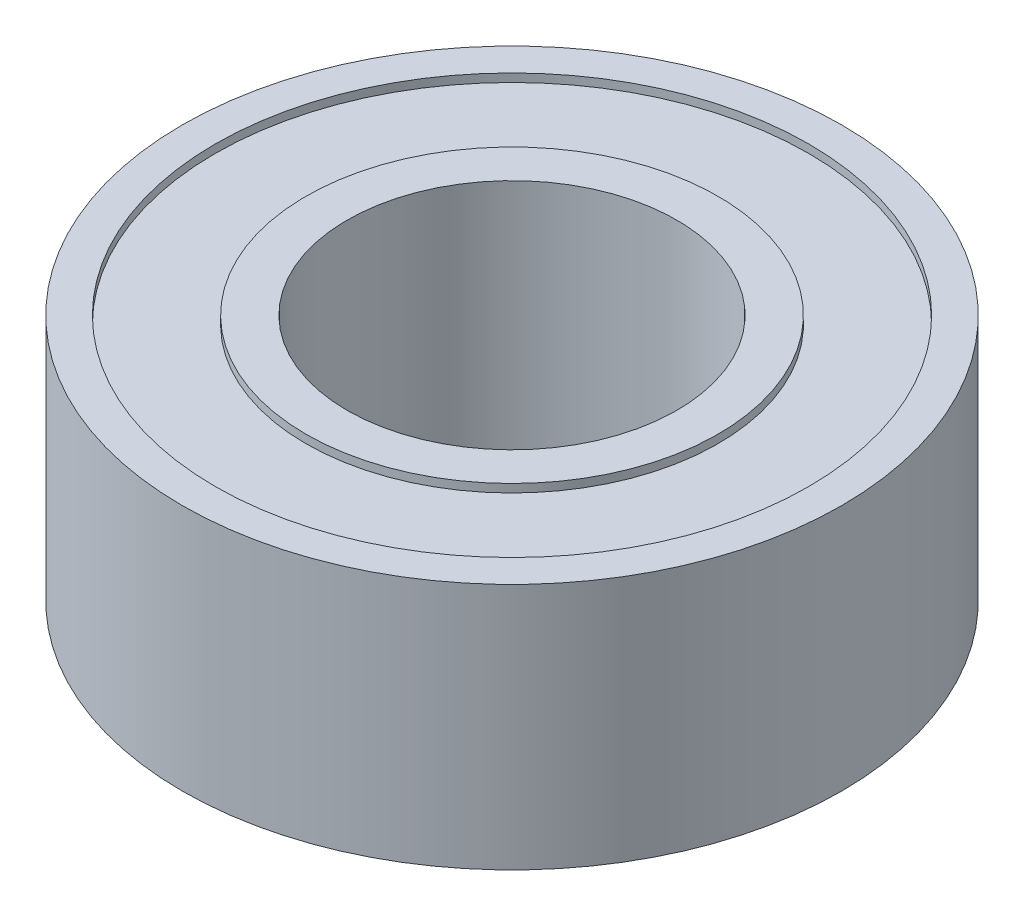
from build123d import *

# Parameters (mm, degrees)
SKETCH_1_R          = 4
SKETCH_1_R_2        = 2
EXTRUDE_1_DEPTH     = 3
SKETCH_2_R          = 3.6
SKETCH_2_R_2        = 2.5
CUT_EXTRUDE_1_DEPTH = 0.1
SKETCH_3_R          = 3.6
SKETCH_3_R_2        = 2.5
CUT_EXTRUDE_2_DEPTH = 0.1


with BuildPart() as part:
    # Эскиз1 → Бобышка-Вытянуть1 (new body)
    with BuildSketch(Plane(origin=(0, 0, 0), x_dir=(1, 0, 0), z_dir=(0, 1, 0))):
        Circle(SKETCH_1_R)
        Circle(SKETCH_1_R_2, mode=Mode.SUBTRACT)
    extrude(amount=EXTRUDE_1_DEPTH)

    # Эскиз2 → Вырез-Вытянуть1 (cut)
    with BuildSketch(Plane(origin=(0, 3, 0), x_dir=(1, 0, 0), z_dir=(0, 1, 0))):
        Circle(SKETCH_2_R)
        Circle(SKETCH_2_R_2, mode=Mode.SUBTRACT)
    extrude(amount=-CUT_EXTRUDE_1_DEPTH, mode=Mode.SUBTRACT)

    # Эскиз3 → Вырез-Вытянуть2 (cut)
    with BuildSketch(Plane.XZ):
        Circle(SKETCH_3_R)
        Circle(SKETCH_3_R_2, mode=Mode.SUBTRACT)
    extrude(amount=-CUT_EXTRUDE_2_DEPTH, mode=Mode.SUBTRACT)


solid = part.part
